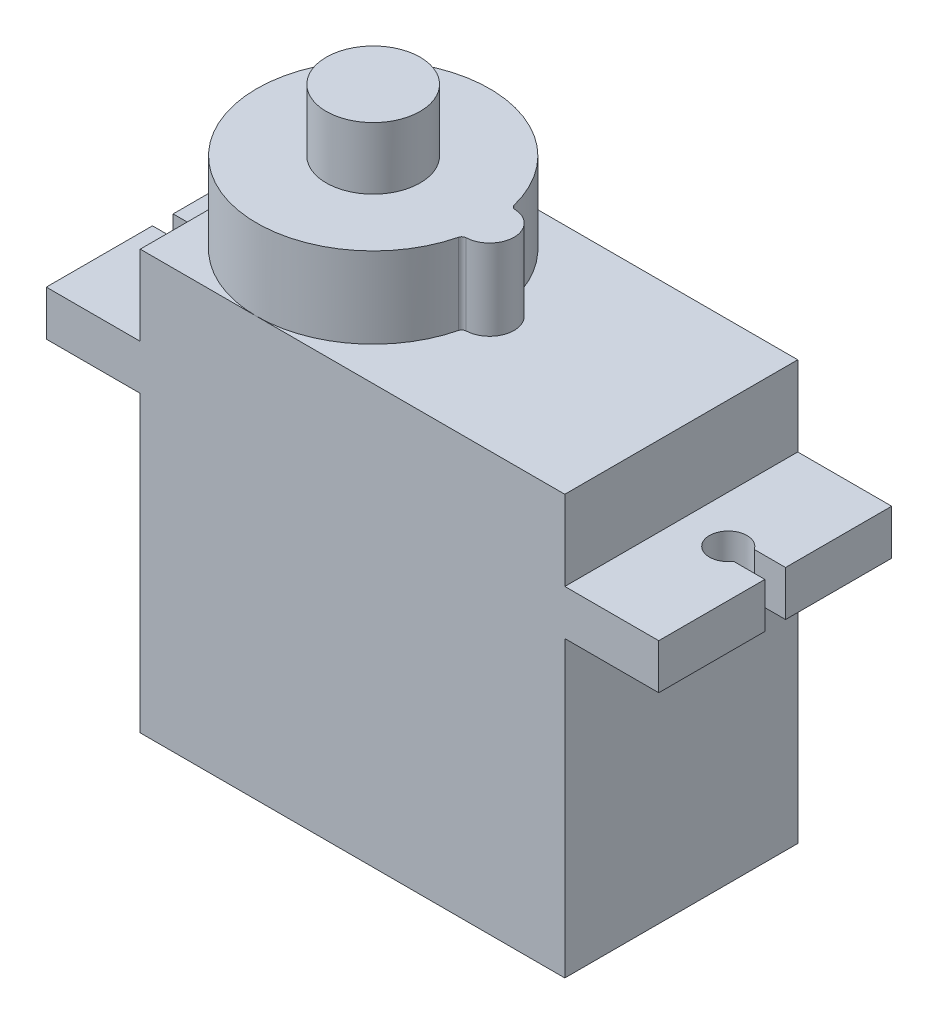
from build123d import *

# Parameters (mm, degrees)
SKETCH3_W             = 22.6
SKETCH3_H             = 12.4
BOSS_EXTRUDE1_DEPTH   = 22.3
SKETCH4_W             = 5
SKETCH4_H             = 2.4
BOSS_EXTRUDE2_DEPTH   = 12.4
CUT_EXTRUDE1_DEPTH    = 22.3
BOSS_EXTRUDE3_DEPTH   = 4.3
SKETCH8_R             = 2.5
BOSS_EXTRUDE4_DEPTH   = 3.3
SKETCH9_R             = 0.6
BOSS_EXTRUDE6_DEPTH   = 3.3
BOSS_EXTRUDE6_2_DEPTH = 3.3
BOSS_EXTRUDE6_3_DEPTH = 3.3


with BuildPart() as part:
    # Sketch3 → Boss-Extrude1 (new body)
    with BuildSketch(Plane(origin=(0, 0, 0), x_dir=(1, 0, 0), z_dir=(0, 1, 0))):
        Rectangle(SKETCH3_W, SKETCH3_H)
    extrude(amount=BOSS_EXTRUDE1_DEPTH)

    # Sketch4 → Boss-Extrude2 (add)
    with BuildSketch(Plane.XY.offset(6.2)):
        with Locations((13.8, 16.85)):
            Rectangle(SKETCH4_W, SKETCH4_H)
        with Locations((-13.8, 16.85)):
            Rectangle(SKETCH4_W, SKETCH4_H)
    extrude(amount=-BOSS_EXTRUDE2_DEPTH)

    # Sketch5 → Cut-Extrude1 (cut)
    with BuildSketch(Plane(origin=(0, 18.05, 0), x_dir=(1, 0, 0), z_dir=(0, 1, 0))):
        with BuildLine():
            Line((14.635164654, 0.55), (16.3, 0.55))
            Line((16.3, 0.55), (16.3, -0.55))
            Line((16.3, -0.55), (14.635164654, -0.55))
            ThreePointArc((14.635164654, -0.55), (12.8, 0), (14.635164654, 0.55))
        make_face()
    cut_extrude1 = extrude(amount=-CUT_EXTRUDE1_DEPTH, mode=Mode.SUBTRACT)

    # Mirror1: Cut-Extrude1 across plane
    add(cut_extrude1.mirror(Plane(origin=(0, 0, 0), x_dir=(0, 0, 1), z_dir=(1, 0, 0))), mode=Mode.SUBTRACT)

    # Sketch7 → Boss-Extrude3 (add)
    with BuildSketch(Plane(origin=(0, 22.3, 0), x_dir=(1, 0, 0), z_dir=(0, 1, 0))):
        with BuildLine():
            ThreePointArc((0.918604651, 1.488757218), (-11.3, 0), (0.918604651, -1.488757218))
            ThreePointArc((0.918604651, -1.488757218), (1.003329596, -1.355013632), (1.151404787, -1.298983275))
            ThreePointArc((1.151404787, -1.298983275), (2.4, 0), (1.151404787, 1.298983275))
            ThreePointArc((1.151404787, 1.298983275), (1.003329596, 1.355013632), (0.918604651, 1.488757218))
        make_face()
    extrude(amount=BOSS_EXTRUDE3_DEPTH)

    # Sketch8 → Boss-Extrude4 (add)
    with BuildSketch(Plane(origin=(0, 26.6, 0), x_dir=(1, 0, 0), z_dir=(0, 1, 0))):
        with Locations((-5.1, 0)):
            Circle(SKETCH8_R)
    extrude(amount=BOSS_EXTRUDE4_DEPTH)


with BuildPart() as body_2:
    # Sketch9 → Boss-Extrude6 (new body)
    with BuildSketch(Plane.ZY.offset(11.3)):
        with Locations((-1.2, 4.5)):
            Circle(SKETCH9_R)
    extrude(amount=BOSS_EXTRUDE6_DEPTH)


with BuildPart() as body_3:
    # Sketch9 → Boss-Extrude6 2 (new body)
    with BuildSketch(Plane.ZY.offset(11.3)):
        with Locations((0, 4.5)):
            Circle(SKETCH9_R)
    extrude(amount=BOSS_EXTRUDE6_2_DEPTH)


with BuildPart() as body_4:
    # Sketch9 → Boss-Extrude6 3 (new body)
    with BuildSketch(Plane.ZY.offset(11.3)):
        with Locations((1.2, 4.5)):
            Circle(SKETCH9_R)
    extrude(amount=BOSS_EXTRUDE6_3_DEPTH)


solid = Compound([part.part, body_2.part, body_3.part, body_4.part])
